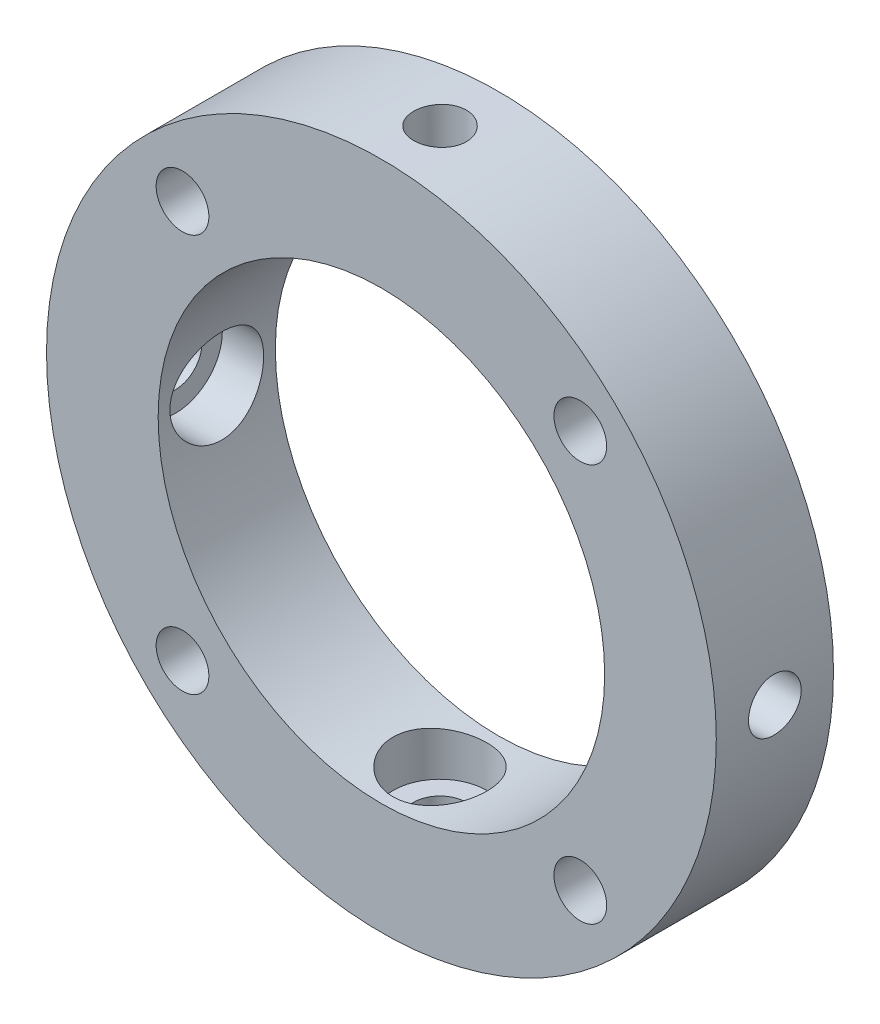
from build123d import *

# Parameters (mm, degrees)
SKETCH1_R           = 28.575
BOSS_EXTRUDE1_DEPTH = 10
SKETCH2_R           = 19.05
CUT_EXTRUDE1_DEPTH  = 11
SKETCH5_R           = 2.25
CUT_EXTRUDE2_DEPTH  = 58.15
SKETCH6_R           = 2.25
CUT_EXTRUDE3_DEPTH  = 11.0000001
CUT_EXTRUDE5_START  = -10
SKETCH7_R           = 4
SKETCH7_R_2         = 2.25
CUT_EXTRUDE5_DEPTH  = 4
CUT_EXTRUDE6_START  = -47.15
SKETCH7_4_R         = 4
SKETCH7_4_R_2       = 2.25
CUT_EXTRUDE6_DEPTH  = 4
CIRPATTERN6_COUNT   = 2
CIRPATTERN6_ANGLE   = 90


with BuildPart() as part:
    # Sketch1 → Boss-Extrude1 (new body)
    with BuildSketch(Plane.XY):
        Circle(SKETCH1_R)
    extrude(amount=BOSS_EXTRUDE1_DEPTH)

    # Sketch2 → Cut-Extrude1 (cut, through all)
    with BuildSketch(Plane.XY.offset(10)):
        Circle(SKETCH2_R)
    extrude(amount=-CUT_EXTRUDE1_DEPTH, mode=Mode.SUBTRACT)

    # Sketch5 → Cut-Extrude2 (cut, through all)
    with BuildSketch(Plane(origin=(0, 28.575, 0), x_dir=(1, 0, 0), z_dir=(0, 1, 0))):
        with Locations((0, -5)):
            Circle(SKETCH5_R)
    cut_extrude2 = extrude(amount=-CUT_EXTRUDE2_DEPTH, mode=Mode.SUBTRACT)

    # Sketch6 → Cut-Extrude3 (cut, through all)
    with BuildSketch(Plane.XY.offset(10)):
        with Locations((-16.970562748, 16.970562748)):
            Circle(SKETCH6_R)
        with Locations((16.970562748, 16.970562748)):
            Circle(SKETCH6_R)
        with Locations((16.970562748, -16.970562748)):
            Circle(SKETCH6_R)
        with Locations((-16.970562748, -16.970562748)):
            Circle(SKETCH6_R)
    extrude(amount=-CUT_EXTRUDE3_DEPTH, mode=Mode.SUBTRACT)

    # Sketch7 → Cut-Extrude5 (cut)
    with BuildSketch(Plane(origin=(0, 28.575, 0), x_dir=(1, 0, 0), z_dir=(0, 1, 0)).offset(CUT_EXTRUDE5_START)):
        with Locations((0, -5)):
            Circle(SKETCH7_R)
        with Locations((0, -5)):
            Circle(SKETCH7_R_2, mode=Mode.SUBTRACT)
    cut_extrude5 = extrude(amount=CUT_EXTRUDE5_DEPTH, mode=Mode.SUBTRACT)

    # Sketch7_4 → Cut-Extrude6 (cut)
    with BuildSketch(Plane(origin=(0, 28.575, 0), x_dir=(1, 0, 0), z_dir=(0, 1, 0)).offset(CUT_EXTRUDE6_START)):
        with Locations((0, -5)):
            Circle(SKETCH7_4_R)
        with Locations((0, -5)):
            Circle(SKETCH7_4_R_2, mode=Mode.SUBTRACT)
    cut_extrude6 = extrude(amount=-CUT_EXTRUDE6_DEPTH, mode=Mode.SUBTRACT)

    # CirPattern6: Cut-Extrude2, Cut-Extrude5, Cut-Extrude6 ×2 about axis
    cirpattern6_axis = Axis((0, 0, 10), (0, 0, 1))
    for i in range(1, CIRPATTERN6_COUNT):
        add(cut_extrude2.rotate(cirpattern6_axis, i * CIRPATTERN6_ANGLE / (CIRPATTERN6_COUNT - 1)), mode=Mode.SUBTRACT)
        add(cut_extrude5.rotate(cirpattern6_axis, i * CIRPATTERN6_ANGLE / (CIRPATTERN6_COUNT - 1)), mode=Mode.SUBTRACT)
        add(cut_extrude6.rotate(cirpattern6_axis, i * CIRPATTERN6_ANGLE / (CIRPATTERN6_COUNT - 1)), mode=Mode.SUBTRACT)


solid = part.part
